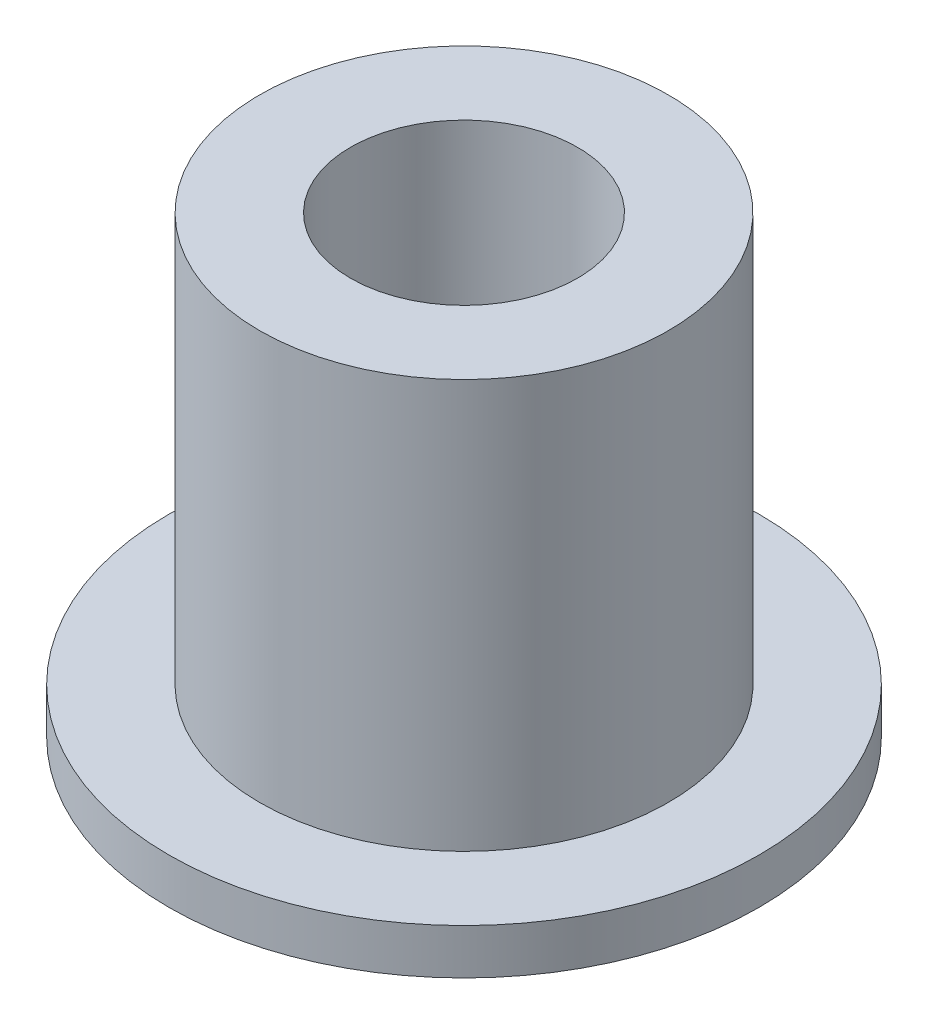
from build123d import *

# Parameters (mm, degrees)
SKETCH1_R           = 4.5
SKETCH1_R_2         = 2.5
BOSS_EXTRUDE1_DEPTH = 10
SKETCH1_3_R         = 6.5
SKETCH1_3_R_2       = 4.5
BOSS_EXTRUDE2_DEPTH = 1


with BuildPart() as part:
    # Sketch1 → Boss-Extrude1 (new body)
    with BuildSketch(Plane(origin=(0, 0, 0), x_dir=(1, 0, 0), z_dir=(0, 1, 0))):
        Circle(SKETCH1_R)
        Circle(SKETCH1_R_2, mode=Mode.SUBTRACT)
    extrude(amount=BOSS_EXTRUDE1_DEPTH)

    # Sketch1_3 → Boss-Extrude2 (add)
    with BuildSketch(Plane(origin=(0, 0, 0), x_dir=(1, 0, 0), z_dir=(0, 1, 0))):
        Circle(SKETCH1_3_R)
        Circle(SKETCH1_3_R_2, mode=Mode.SUBTRACT)
    extrude(amount=BOSS_EXTRUDE2_DEPTH)


solid = part.part
